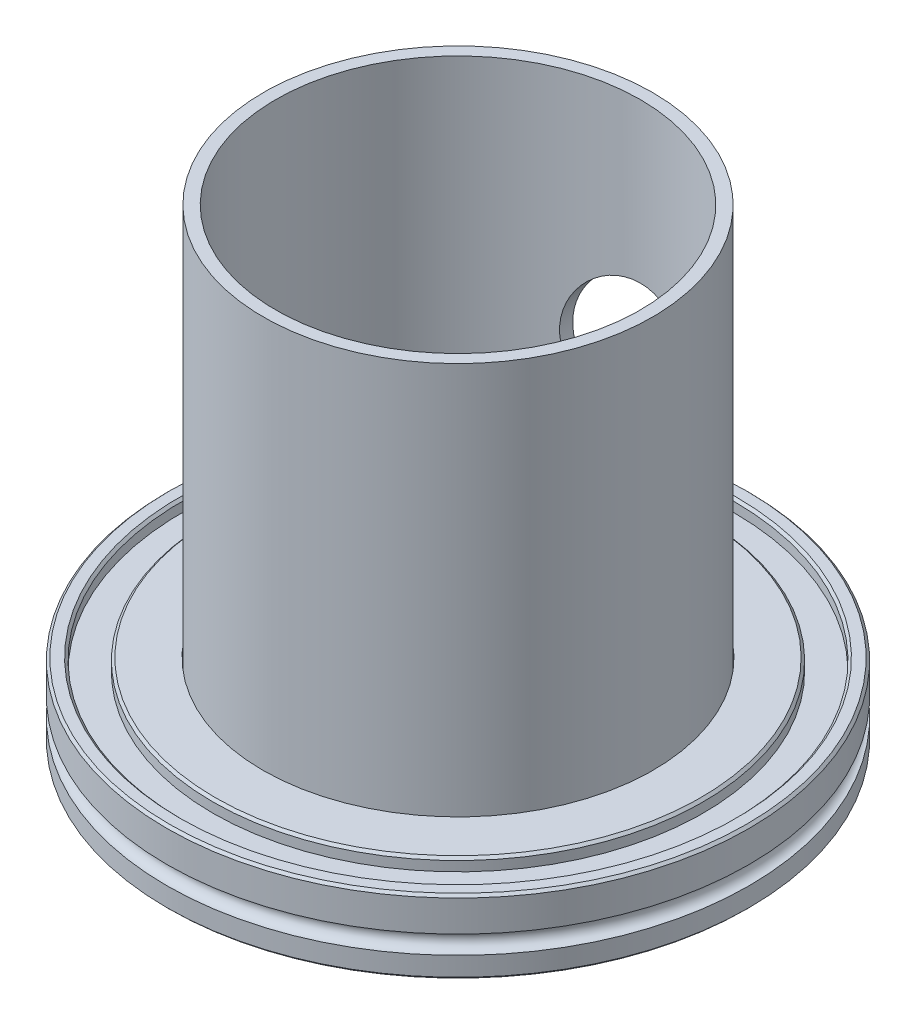
from build123d import *

# Parameters (mm, degrees)
SKETCH7_W          = 2
SKETCH7_H          = 69.5
SKETCH9_R          = 11.05
CUT_EXTRUDE1_DEPTH = 48.5


with BuildPart() as part:
    # Sketch5 → ISO-63K (revolve)
    with BuildSketch(Plane(origin=(0, 0, 0), x_dir=(-1, 0, 0), z_dir=(0, 0, -1))):
        with BuildLine():
            Line((-47.1, 12), (-47.5, 11.6))
            Line((-47.5, 11.6), (-47.5, 6.5))
            ThreePointArc((-47.5, 6.5), (-46, 5), (-47.5, 3.5))
            Line((-47.5, 3.5), (-47.5, 0.4))
            Line((-47.5, 0.4), (-47.1, 0))
            Line((-47.1, 0), (-35.4, 0))
            Line((-35.4, 0), (-35, 0.4))
            Line((-35, 0.4), (-35, 4.5))
            Line((-35, 4.5), (-30.15, 4.5))
            Line((-30.15, 4.5), (-30.15, 6.5))
            Line((-30.15, 6.5), (-31.85, 6.5))
            Line((-31.85, 6.5), (-31.85, 12))
            Line((-31.85, 12), (-39.6, 12))
            Line((-39.6, 12), (-40, 11.6))
            Line((-40, 11.6), (-40, 10))
            Line((-40, 10), (-45, 10))
            Line((-45, 10), (-45, 11.6))
            Line((-45, 11.6), (-45.4, 12))
            Line((-45.4, 12), (-47.1, 12))
        make_face()
    revolve(axis=Axis((0, 0, 0), (0, 1, 0)))


with BuildPart() as body_2:
    # Sketch7 → Half-Nipple (revolve)
    with BuildSketch(Plane.XY):
        with Locations((30.75, 41.25)):
            Rectangle(SKETCH7_W, SKETCH7_H)
    revolve(axis=Axis((0, 88, 0), (0, -1, 0)))

    # Sketch9 → Cut-Extrude1 (cut, through all)
    with BuildSketch(Plane.XY):
        with Locations((0, 39)):
            Circle(SKETCH9_R)
    extrude(amount=-CUT_EXTRUDE1_DEPTH, mode=Mode.SUBTRACT)


solid = Compound([part.part, body_2.part])
